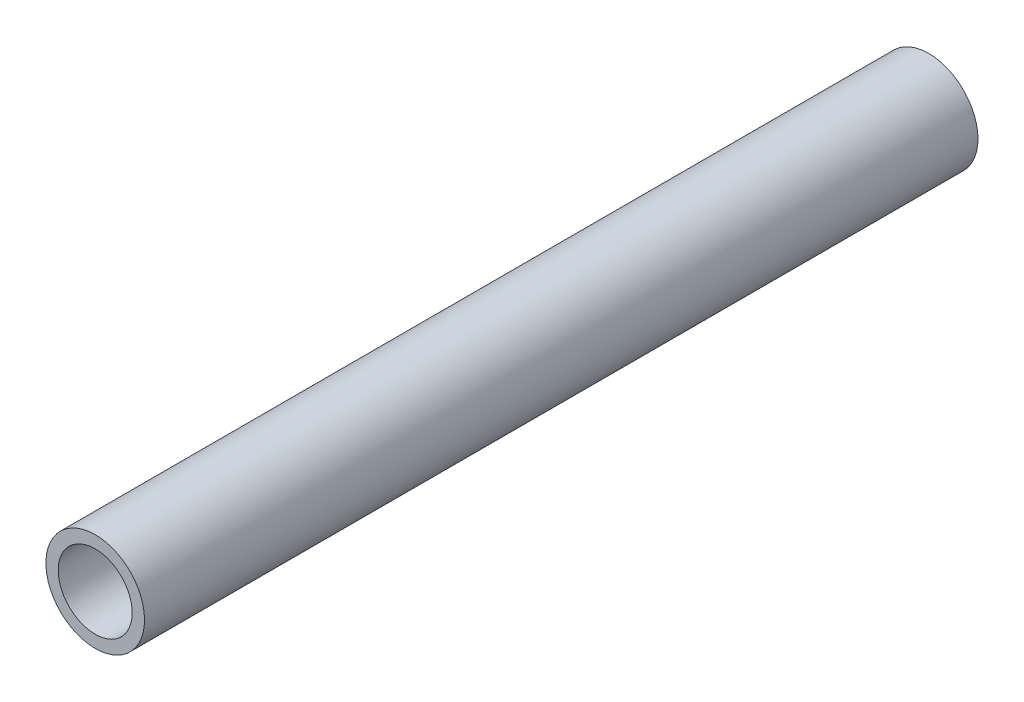
from build123d import *

# Parameters (mm, degrees)
SKETCH1_R      = 12.7
SKETCH1_R_2    = 9.525
EXTRUDE1_DEPTH = 107.34675


with BuildPart() as part:
    # Sketch1 → Extrude1 (new body, symmetric)
    with BuildSketch(Plane.XY):
        Circle(SKETCH1_R)
        Circle(SKETCH1_R_2, mode=Mode.SUBTRACT)
    extrude(amount=EXTRUDE1_DEPTH, both=True)


solid = part.part
